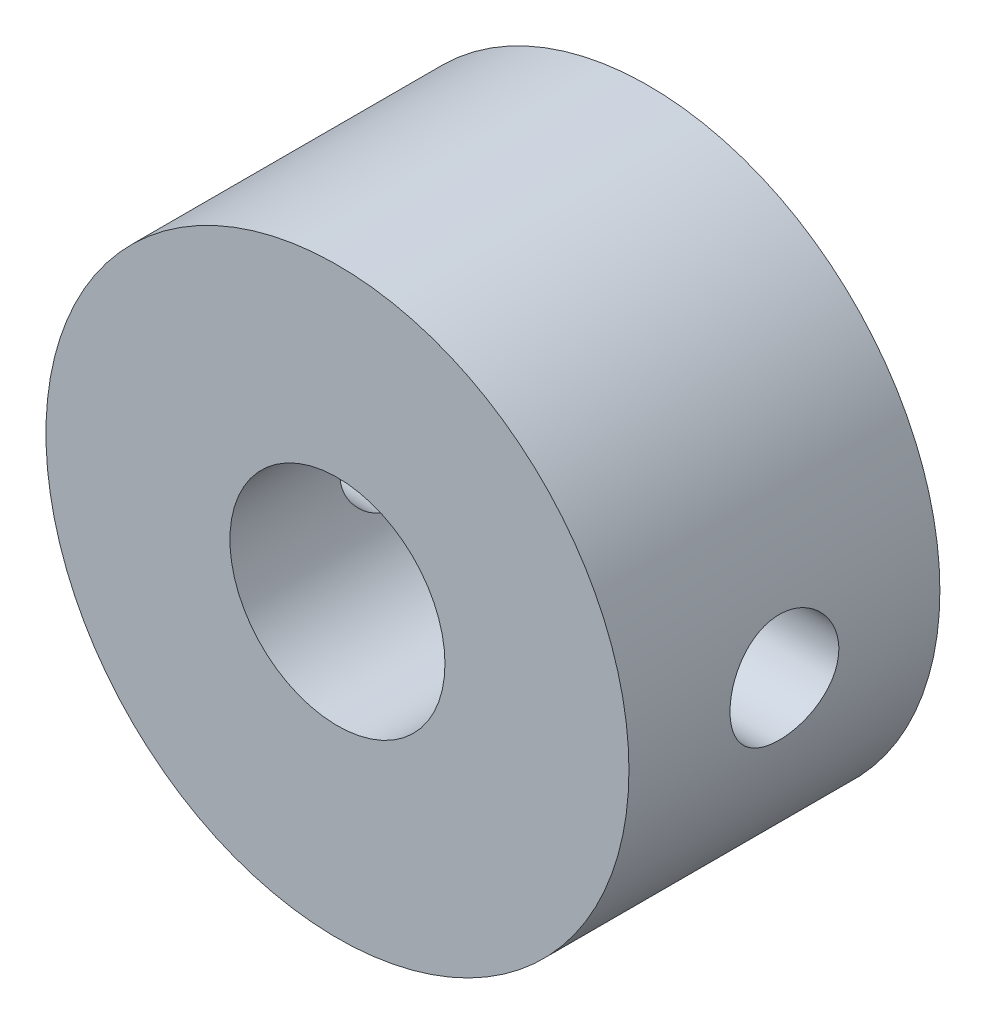
from build123d import *

# Parameters (mm, degrees)
SKETCH1_R           = 11.25
BOSS_EXTRUDE1_DEPTH = 12
SKETCH2_R           = 4.15
CUT_EXTRUDE1_DEPTH  = 15
SKETCH3_R           = 2.1
CUT_EXTRUDE2_DEPTH  = 5
SKETCH4_R           = 1.75
CUT_EXTRUDE3_DEPTH  = 18.5000001


with BuildPart() as part:
    # Sketch1 → Boss-Extrude1 (new body)
    with BuildSketch(Plane.XY):
        Circle(SKETCH1_R)
    extrude(amount=BOSS_EXTRUDE1_DEPTH)

    # Sketch2 → Cut-Extrude1 (cut)
    with BuildSketch(Plane.XY.offset(12)):
        Circle(SKETCH2_R)
    extrude(amount=-CUT_EXTRUDE1_DEPTH, mode=Mode.SUBTRACT)

    # Sketch3 → Cut-Extrude2 (cut)
    with BuildSketch(Plane(origin=(-11.25, 0, 0), x_dir=(0, 0, -1), z_dir=(1, 0, 0))):
        with Locations((-6, 0)):
            Circle(SKETCH3_R)
    cut_extrude2 = extrude(amount=CUT_EXTRUDE2_DEPTH, mode=Mode.SUBTRACT)

    # Sketch4 → Cut-Extrude3 (cut, through all)
    with BuildSketch(Plane.ZY.offset(6.25)):
        with Locations((6, 0)):
            Circle(SKETCH4_R)
    extrude(amount=-CUT_EXTRUDE3_DEPTH, mode=Mode.SUBTRACT)

    # Mirror1: Cut-Extrude2 across plane
    add(cut_extrude2.mirror(Plane(origin=(0, 0, 0), x_dir=(0, 0, 1), z_dir=(1, 0, 0))), mode=Mode.SUBTRACT)


solid = part.part
